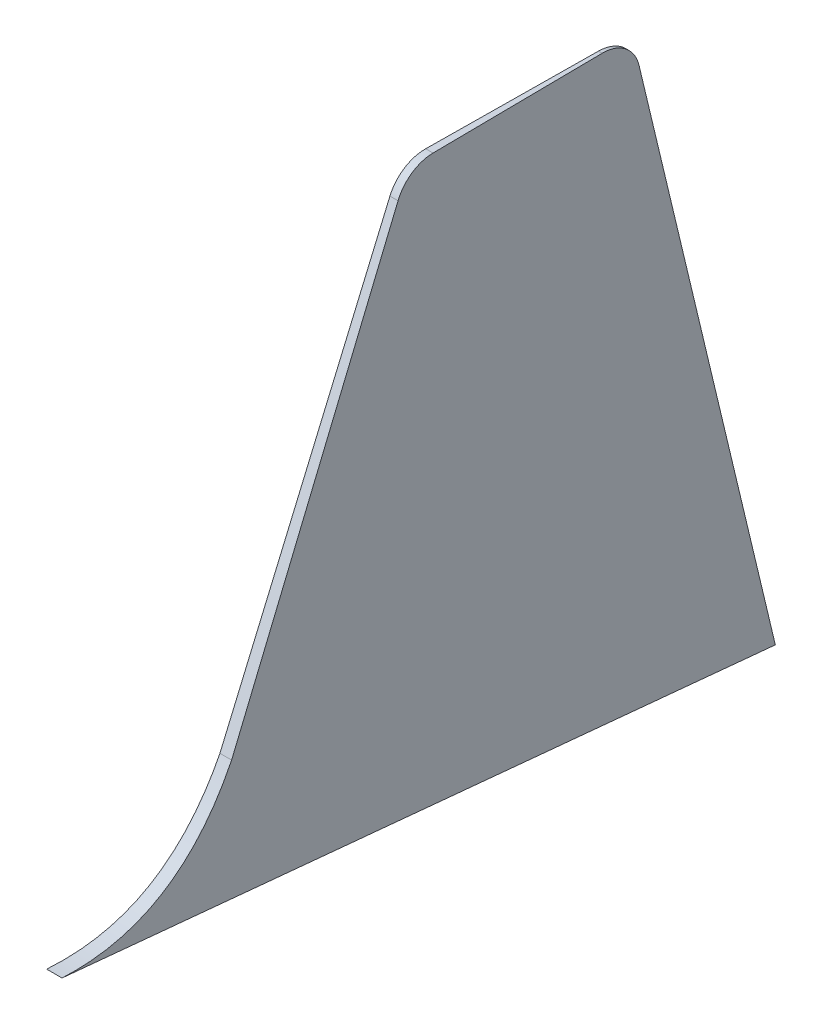
from build123d import *

# Parameters (mm, degrees)
BOSS_EXTRUDE2_DEPTH = 30
SKETCH2_OUTSIDE_W   = 398.982
SKETCH2_OUTSIDE_H   = 1778.443
CUT_EXTRUDE3_DEPTH  = 1682.417983347


with BuildPart() as part:
    # Sketch1 → Boss-Extrude2 (new body)
    with BuildSketch(Plane(origin=(0, 0, 0), x_dir=(0, 0, -1), z_dir=(1, 0, 0))):
        with BuildLine():
            add(Edge.make_bspline(
                [(317.332343648, 655.186668482), (545.117144099, 641.097671469), (652.446570925, 854.768900431)],
                knots=[0.084059477, 0.084059477, 0.084059477, 1, 1, 1], degree=2))
            Line((317.332343648, 655.186668482), (1726.792532284, 506.936901497))
            Line((1726.792532284, 506.936901497), (1457.519541354, 1623.993731145))
            ThreePointArc((1457.519541354, 1623.993731145), (1431.012841469, 1665.338188153), (1384.60799847, 1681.417983247))
            Line((1384.60799847, 1681.417983247), (1050.440765915, 1681.417983247))
            ThreePointArc((1050.440765915, 1681.417983247), (1008.959277853, 1668.902270457), (981.322333542, 1635.532280531))
            Line((981.322333542, 1635.532280531), (652.446570925, 854.768900431))
        make_face()
    extrude(amount=BOSS_EXTRUDE2_DEPTH)

    # Sketch2 outside → Cut-Extrude3 (cut, through all)
    with BuildSketch(Plane(origin=(0, 0, 0), x_dir=(1, 0, 0), z_dir=(0, 1, 0))):
        with Locations((15, 1022.0625)):
            Rectangle(SKETCH2_OUTSIDE_W, SKETCH2_OUTSIDE_H)
        Polygon((15, 1726.792532284), (0, 317.332343643), (30, 317.332343643), align=None, mode=Mode.SUBTRACT)
    extrude(amount=CUT_EXTRUDE3_DEPTH, mode=Mode.SUBTRACT)


solid = part.part
